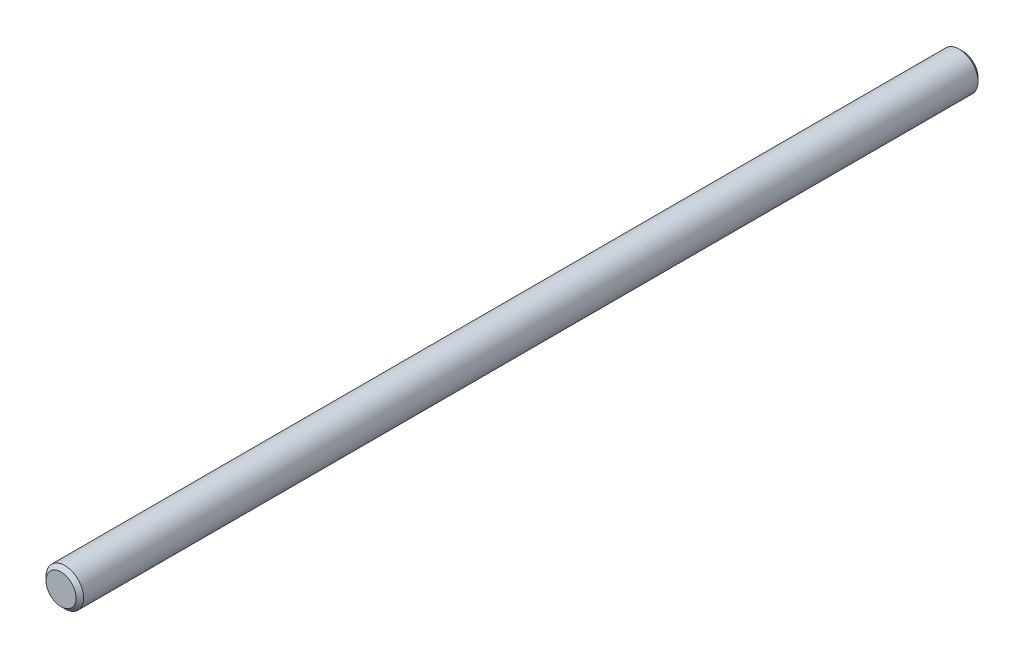
from build123d import *

# Parameters (mm, degrees)
SKETCH3_R           = 1.5875
BOSS_EXTRUDE1_DEPTH = 38.1
CHAMFER1_SIZE       = 0.3175


with BuildPart() as part:
    # Sketch3 → Boss-Extrude1 (new body, symmetric)
    with BuildSketch(Plane.XY):
        Circle(SKETCH3_R)
    extrude(amount=BOSS_EXTRUDE1_DEPTH, both=True)

    # Chamfer1
    chamfer1_edges = [part.edges().sort_by_distance(p)[0] for p in [
        (-1.5875, 0, -38.1),
        (-1.5875, 0, 38.1),
    ]]
    chamfer(chamfer1_edges, length=CHAMFER1_SIZE)


solid = part.part
